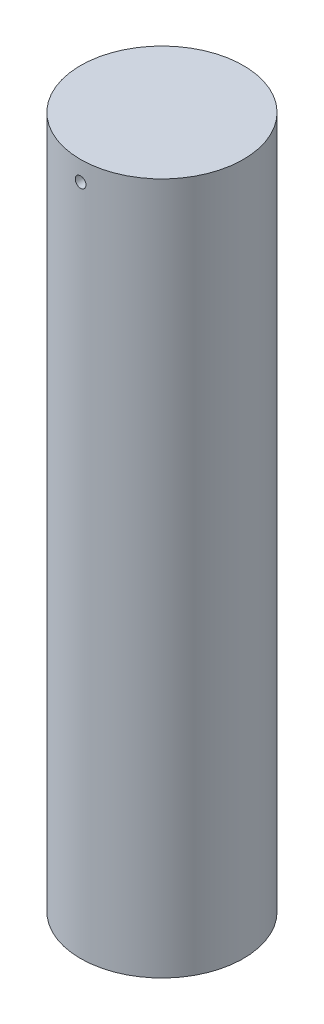
from build123d import *

# Parameters (mm, degrees)
SKETCH1_R                   = 6.35
BOSS_EXTRUDE1_DEPTH         = 53.975
F_1_4_20_TAPPED_HOLE1_D     = 5.1054
F_1_4_20_TAPPED_HOLE1_DEPTH = 25.4
F_1_4_20_TAPPED_HOLE1_TIP   = 1.533816902
F_66_0_033_DIAMETER_HOLE1_D = 0.8382


with BuildPart() as part:
    # Sketch1 → Boss-Extrude1 (new body)
    with BuildSketch(Plane(origin=(0, 0, 0), x_dir=(1, 0, 0), z_dir=(0, 1, 0))):
        Circle(SKETCH1_R)
    extrude(amount=BOSS_EXTRUDE1_DEPTH)

    # 1/4-20 Tapped Hole1
    with Locations(Plane(origin=(0, 0, 0), x_dir=(-1, 0, 0), z_dir=(0, -1, 0))):
        with Locations((0, 0)):
            Hole(F_1_4_20_TAPPED_HOLE1_D / 2, depth=F_1_4_20_TAPPED_HOLE1_DEPTH)
            with Locations((0, 0, -(F_1_4_20_TAPPED_HOLE1_DEPTH + F_1_4_20_TAPPED_HOLE1_TIP / 2))):  # 118° drill point
                Cone(0, F_1_4_20_TAPPED_HOLE1_D / 2, F_1_4_20_TAPPED_HOLE1_TIP, mode=Mode.SUBTRACT)

    # #66 (0.033) Diameter Hole1 (through all)
    with Locations(Plane(origin=(-0.006974239, 52.448108519, 6.34999617), x_dir=(0.999999397, 0, 0.001098305), z_dir=(-0.001098305, 0, 0.999999397))):
        with Locations((0, 0)):
            Hole(F_66_0_033_DIAMETER_HOLE1_D / 2)


solid = part.part
